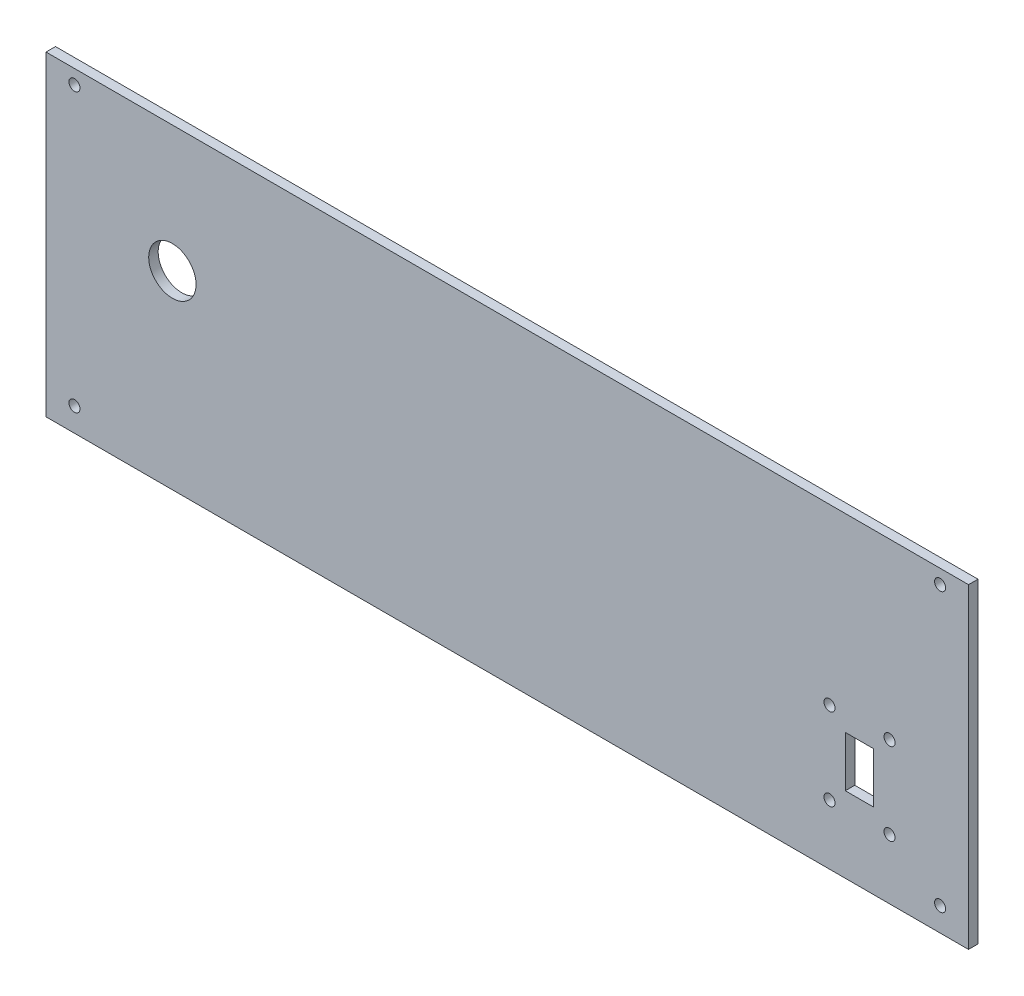
from build123d import *

# Parameters (mm, degrees)
SKETCH1_W           = 300
SKETCH1_H           = 100
BOSS_EXTRUDE1_DEPTH = 3
SKETCH3_W           = 8
SKETCH3_H           = 100
CUT_EXTRUDE2_DEPTH  = 10
SKETCH4_R           = 1.75
CUT_EXTRUDE3_DEPTH  = 4
SKETCH5_R           = 7.5
CUT_EXTRUDE4_DEPTH  = 10
SKETCH6_R           = 1.75
SKETCH6_W           = 9
SKETCH6_H           = 16
CUT_EXTRUDE5_DEPTH  = 10


with BuildPart() as part:
    # Sketch1 → Boss-Extrude1 (new body)
    with BuildSketch(Plane.XY):
        with Locations((150, 50)):
            Rectangle(SKETCH1_W, SKETCH1_H)
    extrude(amount=BOSS_EXTRUDE1_DEPTH)

    # Sketch3 → Cut-Extrude2 (cut)
    with BuildSketch(Plane(origin=(0, 0, 0), x_dir=(-1, 0, 0), z_dir=(0, 0, -1))):
        with Locations((-4, 50)):
            Rectangle(SKETCH3_W, SKETCH3_H)
    extrude(amount=-CUT_EXTRUDE2_DEPTH, mode=Mode.SUBTRACT)

    # Sketch4 → Cut-Extrude3 (cut, through all)
    with BuildSketch(Plane(origin=(0, 0, 0), x_dir=(-1, 0, 0), z_dir=(0, 0, -1))):
        with Locations((-291, 95.5)):
            Circle(SKETCH4_R)
        with Locations((-17, 95.5)):
            Circle(SKETCH4_R)
        with Locations((-17, 7.5)):
            Circle(SKETCH4_R)
        with Locations((-291, 7.5)):
            Circle(SKETCH4_R)
    extrude(amount=-CUT_EXTRUDE3_DEPTH, mode=Mode.SUBTRACT)

    # Sketch5 → Cut-Extrude4 (cut)
    with BuildSketch(Plane(origin=(0, 0, 0), x_dir=(-1, 0, 0), z_dir=(0, 0, -1))):
        with Locations((-48, 60)):
            Circle(SKETCH5_R)
    extrude(amount=-CUT_EXTRUDE4_DEPTH, mode=Mode.SUBTRACT)

    # Sketch6 → Cut-Extrude5 (cut)
    with BuildSketch(Plane(origin=(0, 0, 0), x_dir=(-1, 0, 0), z_dir=(0, 0, -1))):
        with Locations((-275, 45)):
            Circle(SKETCH6_R)
        with Locations((-275, 19)):
            Circle(SKETCH6_R)
        with Locations((-256, 19)):
            Circle(SKETCH6_R)
        with Locations((-256, 45)):
            Circle(SKETCH6_R)
        with Locations((-265.5, 32)):
            Rectangle(SKETCH6_W, SKETCH6_H)
    extrude(amount=-CUT_EXTRUDE5_DEPTH, mode=Mode.SUBTRACT)


solid = part.part
